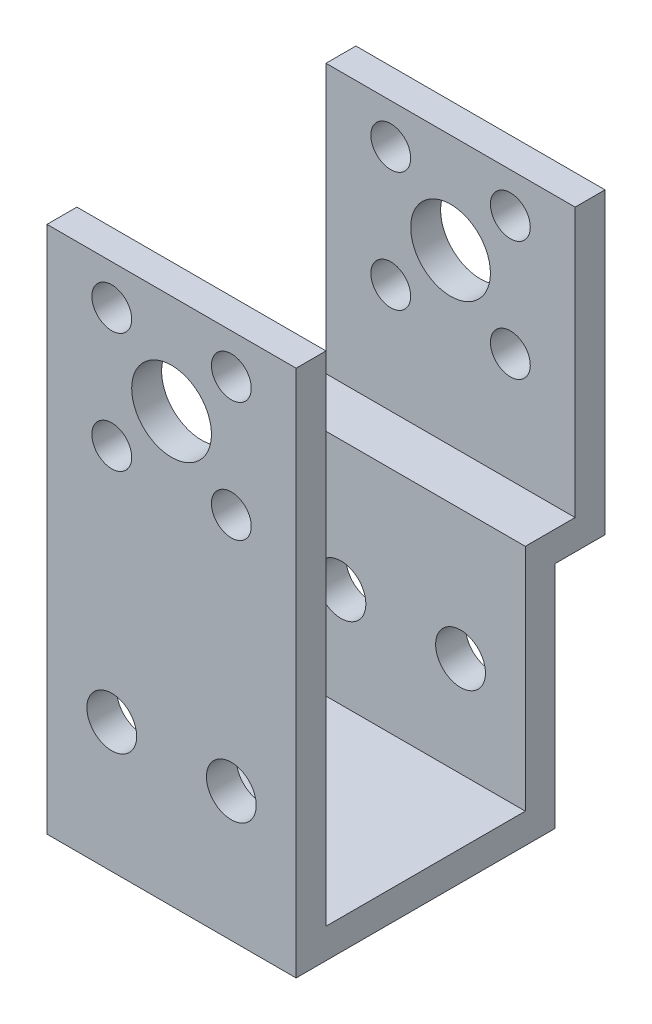
from build123d import *

# Parameters (mm, degrees)
SKETCH_1_W                      = 25
SKETCH_1_H                      = 50
EXTRUDE_1_DEPTH                 = 3
EXTRUDE_2_DEPTH                 = 25
CUT_EXTRUDE_1_REACH             = 5
SKETCH_2_R                      = 2.5
SKETCH_2_R_2                    = 4
SKETCH_2_R_3                    = 2
CUT_EXTRUDE_1_DIRECTION_2_REACH = 30


with BuildPart() as part:
    # 草图1 → 凸台-拉伸1 (new body)
    with BuildSketch(Plane.XY):
        with Locations((12.5, 25)):
            Rectangle(SKETCH_1_W, SKETCH_1_H)
    extrude(amount=EXTRUDE_1_DEPTH)

    # 草图4 → 凸台-拉伸2 (add)
    with BuildSketch(Plane.ZY):
        Polygon((-23, -3), (-23, 20.018133071), (-28, 20.018133071), (-28, 50), (-25, 50), (-25, 23.018133071), (-20, 23.018133071), (-20, 0), (3, 0), (3, -3), align=None)
    extrude(amount=-EXTRUDE_2_DEPTH)

    # 草图2 → 切除-拉伸1 (cut, up to next)
    with BuildSketch(Plane(origin=(0, 0, 0), x_dir=(-1, 0, 0), z_dir=(0, 0, -1)), mode=Mode.PRIVATE) as cut_extrude_1_sk1:
        with Locations((-18.5, 10)):
            Circle(SKETCH_2_R)
    cut_extrude_1_tool1 = extrude(cut_extrude_1_sk1.sketch, amount=-CUT_EXTRUDE_1_REACH, mode=Mode.PRIVATE) & part.part
    add(cut_extrude_1_tool1.solids().sort_by_distance((18.5, 10, 0))[0], mode=Mode.SUBTRACT)
    # 草图2 → 切除-拉伸1 (cut, up to next)
    with BuildSketch(Plane(origin=(0, 0, 0), x_dir=(-1, 0, 0), z_dir=(0, 0, -1)), mode=Mode.PRIVATE) as cut_extrude_1_sk2:
        with Locations((-6.5, 10)):
            Circle(SKETCH_2_R)
    cut_extrude_1_tool2 = extrude(cut_extrude_1_sk2.sketch, amount=-CUT_EXTRUDE_1_REACH, mode=Mode.PRIVATE) & part.part
    add(cut_extrude_1_tool2.solids().sort_by_distance((6.5, 10, 0))[0], mode=Mode.SUBTRACT)
    # 草图2 → 切除-拉伸1 (cut, up to next)
    with BuildSketch(Plane(origin=(0, 0, 0), x_dir=(-1, 0, 0), z_dir=(0, 0, -1)), mode=Mode.PRIVATE) as cut_extrude_1_sk3:
        with Locations((-12.5, 40)):
            Circle(SKETCH_2_R_2)
    cut_extrude_1_tool3 = extrude(cut_extrude_1_sk3.sketch, amount=-CUT_EXTRUDE_1_REACH, mode=Mode.PRIVATE) & part.part
    add(cut_extrude_1_tool3.solids().sort_by_distance((12.5, 40, 0))[0], mode=Mode.SUBTRACT)
    # 草图2 → 切除-拉伸1 (cut, up to next)
    with BuildSketch(Plane(origin=(0, 0, 0), x_dir=(-1, 0, 0), z_dir=(0, 0, -1)), mode=Mode.PRIVATE) as cut_extrude_1_sk4:
        with Locations((-6.5, 46)):
            Circle(SKETCH_2_R_3)
    cut_extrude_1_tool4 = extrude(cut_extrude_1_sk4.sketch, amount=-CUT_EXTRUDE_1_REACH, mode=Mode.PRIVATE) & part.part
    add(cut_extrude_1_tool4.solids().sort_by_distance((6.5, 46, 0))[0], mode=Mode.SUBTRACT)
    # 草图2 → 切除-拉伸1 (cut, up to next)
    with BuildSketch(Plane(origin=(0, 0, 0), x_dir=(-1, 0, 0), z_dir=(0, 0, -1)), mode=Mode.PRIVATE) as cut_extrude_1_sk5:
        with Locations((-6.5, 34)):
            Circle(SKETCH_2_R_3)
    cut_extrude_1_tool5 = extrude(cut_extrude_1_sk5.sketch, amount=-CUT_EXTRUDE_1_REACH, mode=Mode.PRIVATE) & part.part
    add(cut_extrude_1_tool5.solids().sort_by_distance((6.5, 34, 0))[0], mode=Mode.SUBTRACT)
    # 草图2 → 切除-拉伸1 (cut, up to next)
    with BuildSketch(Plane(origin=(0, 0, 0), x_dir=(-1, 0, 0), z_dir=(0, 0, -1)), mode=Mode.PRIVATE) as cut_extrude_1_sk6:
        with Locations((-18.5, 34)):
            Circle(SKETCH_2_R_3)
    cut_extrude_1_tool6 = extrude(cut_extrude_1_sk6.sketch, amount=-CUT_EXTRUDE_1_REACH, mode=Mode.PRIVATE) & part.part
    add(cut_extrude_1_tool6.solids().sort_by_distance((18.5, 34, 0))[0], mode=Mode.SUBTRACT)
    # 草图2 → 切除-拉伸1 (cut, up to next)
    with BuildSketch(Plane(origin=(0, 0, 0), x_dir=(-1, 0, 0), z_dir=(0, 0, -1)), mode=Mode.PRIVATE) as cut_extrude_1_sk7:
        with Locations((-18.5, 46)):
            Circle(SKETCH_2_R_3)
    cut_extrude_1_tool7 = extrude(cut_extrude_1_sk7.sketch, amount=-CUT_EXTRUDE_1_REACH, mode=Mode.PRIVATE) & part.part
    add(cut_extrude_1_tool7.solids().sort_by_distance((18.5, 46, 0))[0], mode=Mode.SUBTRACT)

    # 草图2 → 切除-拉伸1 direction 2 (cut, up to next)
    with BuildSketch(Plane(origin=(0, 0, 0), x_dir=(-1, 0, 0), z_dir=(0, 0, -1)), mode=Mode.PRIVATE) as cut_extrude_1_direction_2_sk1:
        with Locations((-18.5, 10)):
            Circle(SKETCH_2_R)
    cut_extrude_1_direction_2_tool1 = extrude(cut_extrude_1_direction_2_sk1.sketch, amount=CUT_EXTRUDE_1_DIRECTION_2_REACH, mode=Mode.PRIVATE) & part.part
    add(cut_extrude_1_direction_2_tool1.solids().sort_by_distance((18.5, 10, 0))[0], mode=Mode.SUBTRACT)
    # 草图2 → 切除-拉伸1 direction 2 (cut, up to next)
    with BuildSketch(Plane(origin=(0, 0, 0), x_dir=(-1, 0, 0), z_dir=(0, 0, -1)), mode=Mode.PRIVATE) as cut_extrude_1_direction_2_sk2:
        with Locations((-6.5, 10)):
            Circle(SKETCH_2_R)
    cut_extrude_1_direction_2_tool2 = extrude(cut_extrude_1_direction_2_sk2.sketch, amount=CUT_EXTRUDE_1_DIRECTION_2_REACH, mode=Mode.PRIVATE) & part.part
    add(cut_extrude_1_direction_2_tool2.solids().sort_by_distance((6.5, 10, 0))[0], mode=Mode.SUBTRACT)
    # 草图2 → 切除-拉伸1 direction 2 (cut, up to next)
    with BuildSketch(Plane(origin=(0, 0, 0), x_dir=(-1, 0, 0), z_dir=(0, 0, -1)), mode=Mode.PRIVATE) as cut_extrude_1_direction_2_sk3:
        with Locations((-12.5, 40)):
            Circle(SKETCH_2_R_2)
    cut_extrude_1_direction_2_tool3 = extrude(cut_extrude_1_direction_2_sk3.sketch, amount=CUT_EXTRUDE_1_DIRECTION_2_REACH, mode=Mode.PRIVATE) & part.part
    add(cut_extrude_1_direction_2_tool3.solids().sort_by_distance((12.5, 40, 0))[0], mode=Mode.SUBTRACT)
    # 草图2 → 切除-拉伸1 direction 2 (cut, up to next)
    with BuildSketch(Plane(origin=(0, 0, 0), x_dir=(-1, 0, 0), z_dir=(0, 0, -1)), mode=Mode.PRIVATE) as cut_extrude_1_direction_2_sk4:
        with Locations((-6.5, 46)):
            Circle(SKETCH_2_R_3)
    cut_extrude_1_direction_2_tool4 = extrude(cut_extrude_1_direction_2_sk4.sketch, amount=CUT_EXTRUDE_1_DIRECTION_2_REACH, mode=Mode.PRIVATE) & part.part
    add(cut_extrude_1_direction_2_tool4.solids().sort_by_distance((6.5, 46, 0))[0], mode=Mode.SUBTRACT)
    # 草图2 → 切除-拉伸1 direction 2 (cut, up to next)
    with BuildSketch(Plane(origin=(0, 0, 0), x_dir=(-1, 0, 0), z_dir=(0, 0, -1)), mode=Mode.PRIVATE) as cut_extrude_1_direction_2_sk5:
        with Locations((-6.5, 34)):
            Circle(SKETCH_2_R_3)
    cut_extrude_1_direction_2_tool5 = extrude(cut_extrude_1_direction_2_sk5.sketch, amount=CUT_EXTRUDE_1_DIRECTION_2_REACH, mode=Mode.PRIVATE) & part.part
    add(cut_extrude_1_direction_2_tool5.solids().sort_by_distance((6.5, 34, 0))[0], mode=Mode.SUBTRACT)
    # 草图2 → 切除-拉伸1 direction 2 (cut, up to next)
    with BuildSketch(Plane(origin=(0, 0, 0), x_dir=(-1, 0, 0), z_dir=(0, 0, -1)), mode=Mode.PRIVATE) as cut_extrude_1_direction_2_sk6:
        with Locations((-18.5, 34)):
            Circle(SKETCH_2_R_3)
    cut_extrude_1_direction_2_tool6 = extrude(cut_extrude_1_direction_2_sk6.sketch, amount=CUT_EXTRUDE_1_DIRECTION_2_REACH, mode=Mode.PRIVATE) & part.part
    add(cut_extrude_1_direction_2_tool6.solids().sort_by_distance((18.5, 34, 0))[0], mode=Mode.SUBTRACT)
    # 草图2 → 切除-拉伸1 direction 2 (cut, up to next)
    with BuildSketch(Plane(origin=(0, 0, 0), x_dir=(-1, 0, 0), z_dir=(0, 0, -1)), mode=Mode.PRIVATE) as cut_extrude_1_direction_2_sk7:
        with Locations((-18.5, 46)):
            Circle(SKETCH_2_R_3)
    cut_extrude_1_direction_2_tool7 = extrude(cut_extrude_1_direction_2_sk7.sketch, amount=CUT_EXTRUDE_1_DIRECTION_2_REACH, mode=Mode.PRIVATE) & part.part
    add(cut_extrude_1_direction_2_tool7.solids().sort_by_distance((18.5, 46, 0))[0], mode=Mode.SUBTRACT)


solid = part.part
